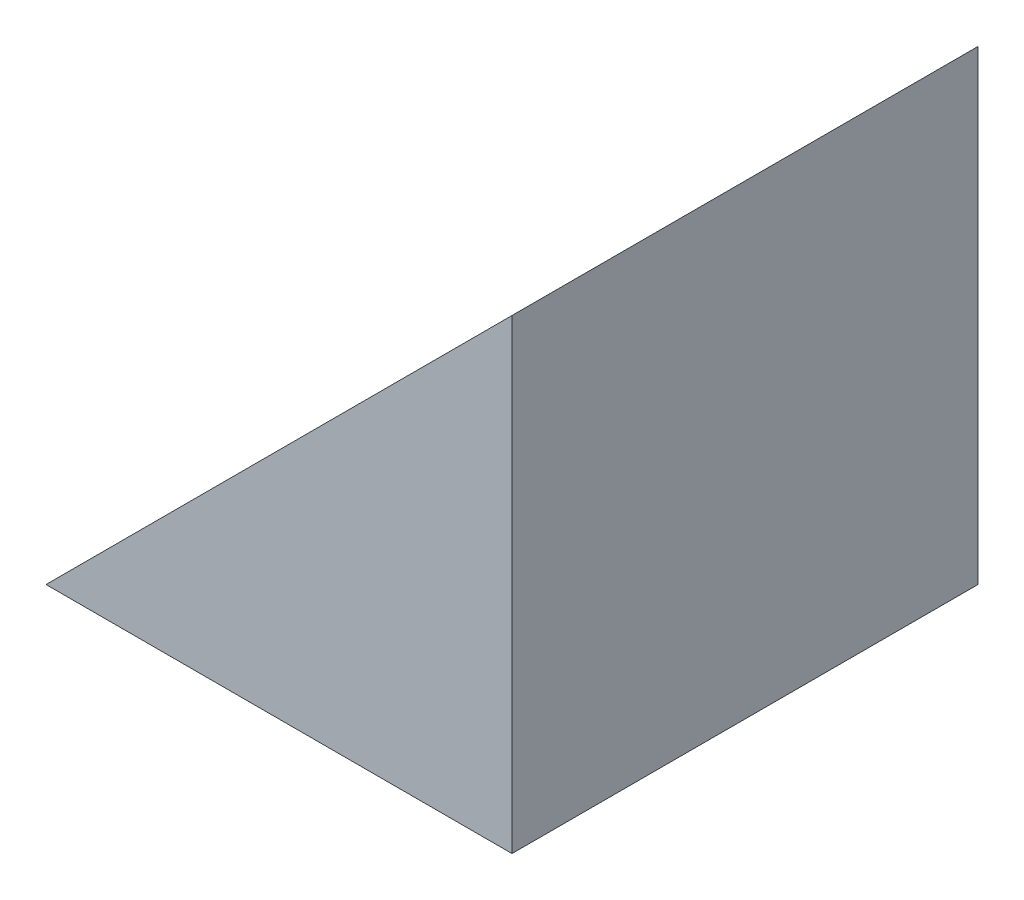
from build123d import *

# Parameters (mm, degrees)
BOSS_EXTRUDE1_DEPTH = 30


with BuildPart() as part:
    # Sketch1 → Boss-Extrude1 (new body)
    with BuildSketch(Plane.XY):
        Polygon((-14.594594595, -17.594594595), (15.405405405, 12.405405405), (15.405405405, -17.594594595), align=None)
    extrude(amount=BOSS_EXTRUDE1_DEPTH)


solid = part.part
